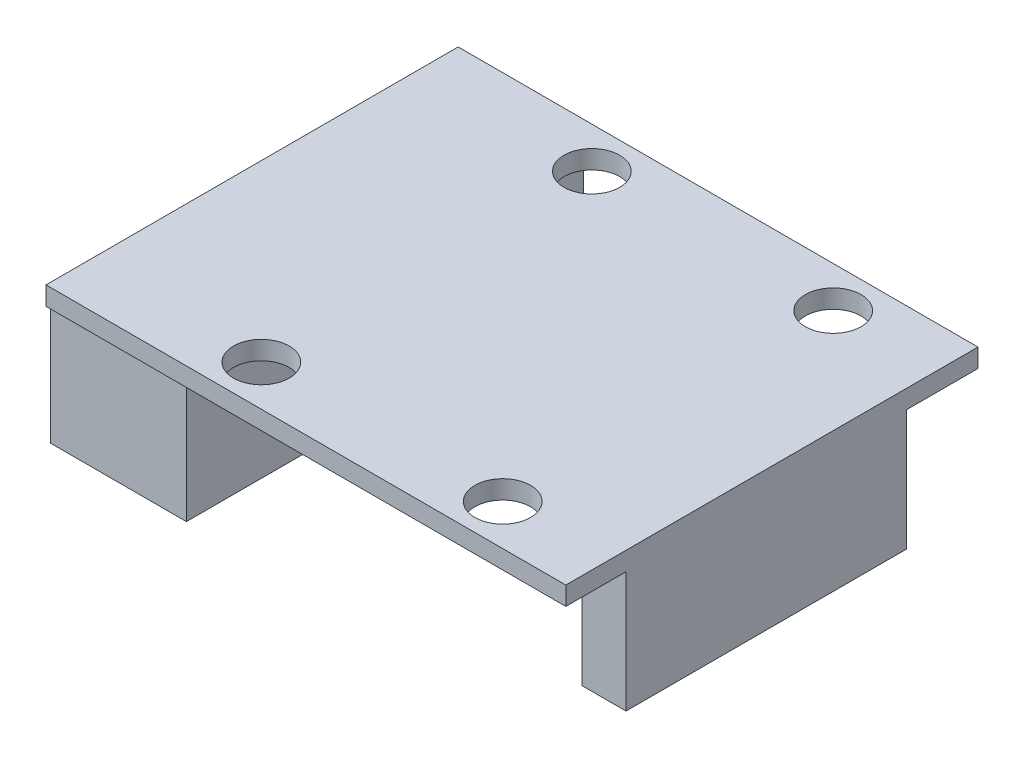
from build123d import *

# Parameters (mm, degrees)
SKETCH1_W           = 28
SKETCH1_H           = 22.2
SKETCH1_R           = 1.5
BOSS_EXTRUDE1_DEPTH = 1
SKETCH2_W           = 7.140567323
SKETCH2_H           = 10.37472735
SKETCH2_W_2         = 7.324889891
SKETCH2_H_2         = 10.322063759
SKETCH2_W_3         = 2.374512373
SKETCH2_H_3         = 15.114450504
BOSS_EXTRUDE2_DEPTH = 6.5


with BuildPart() as part:
    # Sketch1 → Boss-Extrude1 (new body)
    with BuildSketch(Plane(origin=(0, 0, 0), x_dir=(1, 0, 0), z_dir=(0, 1, 0))):
        with Locations((14, 11.1)):
            Rectangle(SKETCH1_W, SKETCH1_H)
        with Locations((9.4, 20)):
            Circle(SKETCH1_R, mode=Mode.SUBTRACT)
        with Locations((22.4, 20)):
            Circle(SKETCH1_R, mode=Mode.SUBTRACT)
        with Locations((22.4, 2.2)):
            Circle(SKETCH1_R, mode=Mode.SUBTRACT)
        with Locations((9.4, 2.2)):
            Circle(SKETCH1_R, mode=Mode.SUBTRACT)
    extrude(amount=BOSS_EXTRUDE1_DEPTH)

    # Sketch2 → Boss-Extrude2 (add)
    with BuildSketch(Plane.XZ):
        with Locations((3.570283662, -16.616511116)):
            Rectangle(SKETCH2_W, SKETCH2_H)
        with Locations((3.662444946, -5.399166316)):
            Rectangle(SKETCH2_W_2, SKETCH2_H_2)
        with Locations((26.812743813, -10.797184354)):
            Rectangle(SKETCH2_W_3, SKETCH2_H_3)
    extrude(amount=BOSS_EXTRUDE2_DEPTH)


solid = part.part
